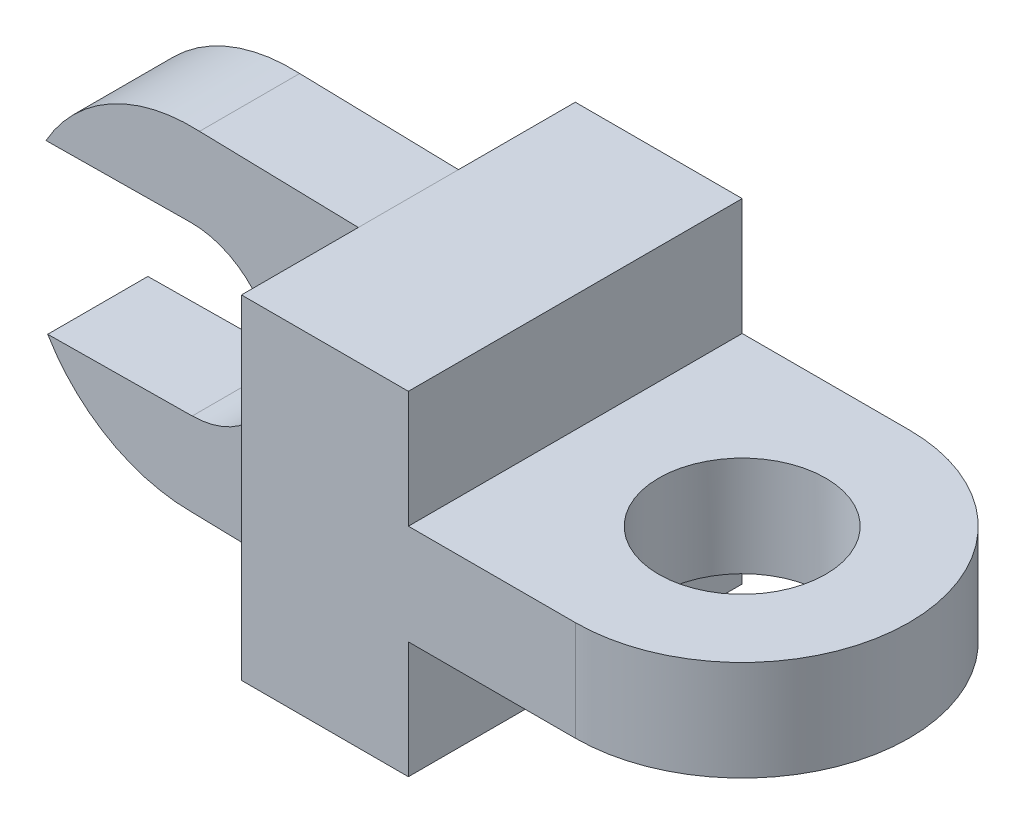
from build123d import *

# Parameters (mm, degrees)
BOSS_EXTRUDE1_DEPTH = 100
SKETCH4_R           = 25
CUT_EXTRUDE2_DEPTH  = 100
SKETCH6_W           = 100.520267533
SKETCH6_H           = 35
CUT_EXTRUDE4_DEPTH  = 100
BOSS_EXTRUDE3_DEPTH = 15
SKETCH11_R          = 25
CUT_EXTRUDE5_DEPTH  = 30
CUT_EXTRUDE6_DEPTH  = 30


with BuildPart() as part:
    # Sketch2 → Boss-Extrude1 (new body)
    with BuildSketch(Plane(origin=(0, 0, 0), x_dir=(1, 0, 0), z_dir=(0, 1, 0))):
        with BuildLine():
            Line((-50, 50), (50, 50))
            ThreePointArc((50, 50), (100, 0), (50, -50))
            Line((50, -50), (-50, -50))
            Line((-50, -50), (-50, 50))
        make_face()
    extrude(amount=BOSS_EXTRUDE1_DEPTH)

    # Sketch4 → Cut-Extrude2 (cut)
    with BuildSketch(Plane(origin=(0, 100, 0), x_dir=(1, 0, 0), z_dir=(0, 1, 0))):
        with Locations((50, 0)):
            Circle(SKETCH4_R)
    extrude(amount=-CUT_EXTRUDE2_DEPTH, mode=Mode.SUBTRACT)

    # Sketch6 → Cut-Extrude4 (cut)
    with BuildSketch(Plane.XY.offset(50)):
        with Locations((50.260133767, 17.5)):
            Rectangle(SKETCH6_W, SKETCH6_H)
        with Locations((50.260133767, 82.5)):
            Rectangle(SKETCH6_W, SKETCH6_H)
    extrude(amount=-CUT_EXTRUDE4_DEPTH, mode=Mode.SUBTRACT)

    # Sketch10 → Boss-Extrude3 (add, symmetric)
    with BuildSketch(Plane.XY):
        with BuildLine():
            Line((-97.564584058, 101.159083353), (-50, 100))
            Line((-50, 100), (-50, 0))
            Line((-50, 0), (-100, 1.218431082))
            ThreePointArc((-100, 1.218431082), (-149.985160866, 52.436500555), (-97.564584058, 101.159083353))
        make_face()
    extrude(amount=BOSS_EXTRUDE3_DEPTH, both=True)

    # Sketch11 → Cut-Extrude5 (cut)
    with BuildSketch(Plane.XY.offset(15)):
        with Locations((-100, 51.218431082)):
            Circle(SKETCH11_R)
    extrude(amount=-CUT_EXTRUDE5_DEPTH, mode=Mode.SUBTRACT)

    # Sketch12 → Cut-Extrude6 (cut)
    with BuildSketch(Plane.XY.offset(15)):
        Polygon((-218.838630954, 25.001308264), (-99.744243338, 26.219739346), (-100.255756662, 76.217122818), (-219.350144278, 74.998691736), align=None)
    extrude(amount=-CUT_EXTRUDE6_DEPTH, mode=Mode.SUBTRACT)


solid = part.part
